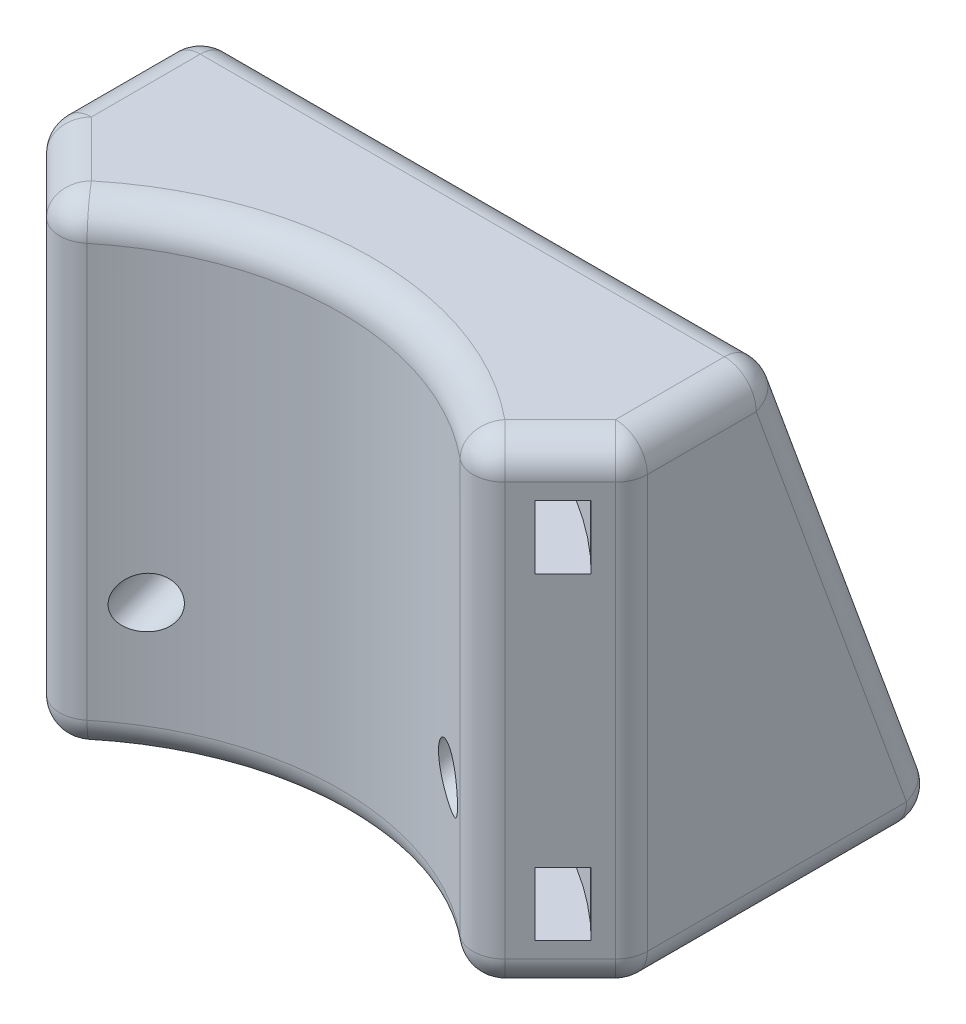
from build123d import *

# Parameters (mm, degrees)
BOSS_EXTRUDE1_DEPTH = 30
SKETCH4_R           = 1.5
CUT_EXTRUDE1_DEPTH  = 24.885599949
FILLET1_R           = 2
SKETCH5_W           = 2.5
SKETCH5_H           = 4


with BuildPart() as part:
    # Sketch3 → Boss-Extrude1 (new body)
    with BuildSketch(Plane(origin=(0, 0, 0), x_dir=(1, 0, 0), z_dir=(0, 1, 0))):
        with BuildLine():
            Line((-18.5, 38.5), (18.5, 38.5))
            Line((18.5, 38.5), (18.5, 18.5))
            Line((18.5, 18.5), (13.081475452, 13.081475452))
            ThreePointArc((13.081475452, 13.081475452), (0, 18.5), (-13.081475452, 13.081475452))
            Line((-13.081475452, 13.081475452), (-18.5, 18.5))
            Line((-18.5, 18.5), (-18.5, 38.5))
        make_face()
    extrude(amount=BOSS_EXTRUDE1_DEPTH)

    # Split1
    split(bisect_by=Plane(origin=(0, 12.373661486, -33.99635553), x_dir=(0, -0.939692621, -0.342020143), z_dir=(0, 0.342020143, -0.939692621)), keep=Keep.BOTTOM)

    # Sketch4 → Cut-Extrude1 (cut, through all)
    with BuildSketch(Plane(origin=(0, 12.373661486, -33.99635553), x_dir=(-1, 0, 0), z_dir=(0, 0.342020143, -0.939692621))):
        with Locations((9.5, 2.794891069)):
            Circle(SKETCH4_R)
        with Locations((-9.5, 2.794891069)):
            Circle(SKETCH4_R)
    extrude(amount=-CUT_EXTRUDE1_DEPTH, mode=Mode.SUBTRACT)

    # Fillet1
    fillet1_edges = [part.edges().sort_by_distance(p)[0] for p in [
        (15.790737726, 0, -15.790737726),
        (18.5, 0, -28.5),
        (-18.5, 0, -28.5),
        (-15.790737726, 0, -15.790737726),
        (0, 0, -18.5),
        (15.790737726, 30, -15.790737726),
        (18.5, 30, -23.040446486),
        (-18.5, 30, -23.040446486),
        (-15.790737726, 30, -15.790737726),
        (0, 30, -18.5),
        (13.081475452, 15, -13.081475452),
        (-13.081475452, 15, -13.081475452),
        (-18.5, 15, -18.5),
        (18.5, 15, -18.5),
        (18.5, 15, -33.040446486),
        (-18.5, 15, -33.040446486),
        (0, 30, -27.580892972),
        (0, 0, -38.5),
    ]]
    fillet(fillet1_edges, radius=FILLET1_R)

    # Sketch5 → Cut-Revolve1 (revolve, cut)
    with BuildSketch(Plane(origin=(0, 0, 0), x_dir=(0, 0, -1), z_dir=(1, 0, 0))):
        with Locations((23, 5)):
            Rectangle(SKETCH5_W, SKETCH5_H)
        with Locations((23, 25)):
            Rectangle(SKETCH5_W, SKETCH5_H)
    revolve(axis=Axis((0, 30, 0), (0, -1, 0)), mode=Mode.SUBTRACT)


solid = part.part
